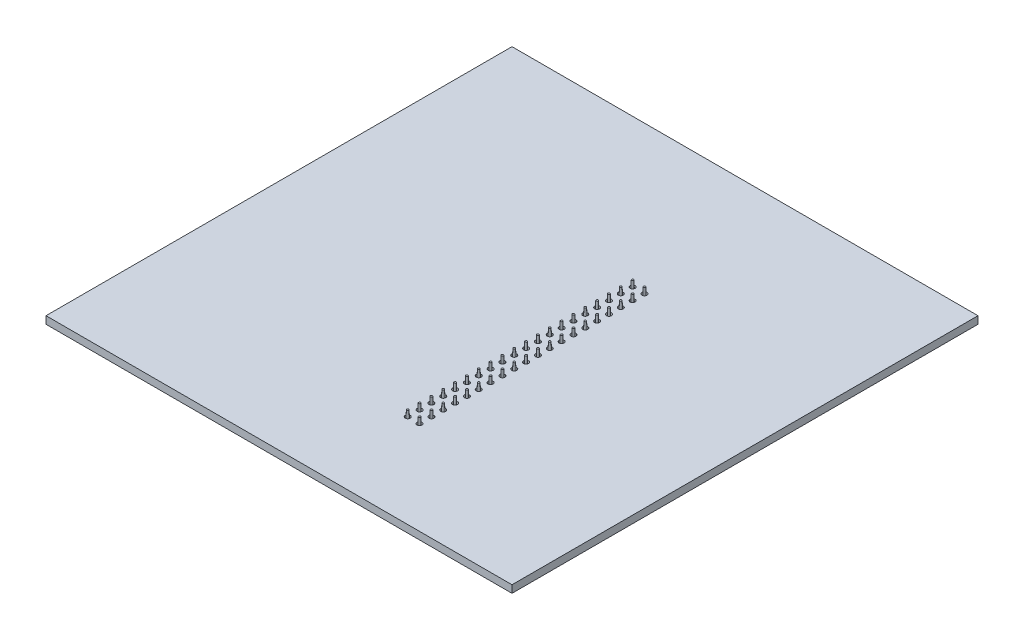
from build123d import *

# Parameters (mm, degrees)
SKETCH1_W              = 100
SKETCH1_H              = 100
BOSS_EXTRUDE1_DEPTH    = 1.6
SKETCH2_R              = 0.535
CUT_EXTRUDE1_DEPTH     = 2.6
SKETCH4_W              = 2.54
SKETCH4_H              = 2.54
SKETCH4_W_2            = 1.54
SKETCH4_H_2            = 1.54
BOSS_EXTRUDE2_DEPTH    = 8.4
LPATTERN2_COUNT        = 20
LPATTERN2_PITCH        = 2.54
LPATTERN2_COUNT_DIR2   = 2
LPATTERN2_PITCH_DIR2   = 2.54
SKETCH5_R              = 0.535
BOSS_EXTRUDE3_DEPTH    = 12.3
BOSS_EXTRUDE3_TAPER    = 1.5
BOSS_EXTRUDE3_2_DEPTH  = 12.3
BOSS_EXTRUDE3_2_TAPER  = 1.5
BOSS_EXTRUDE3_3_DEPTH  = 12.3
BOSS_EXTRUDE3_3_TAPER  = 1.5
BOSS_EXTRUDE3_4_DEPTH  = 12.3
BOSS_EXTRUDE3_4_TAPER  = 1.5
BOSS_EXTRUDE3_5_DEPTH  = 12.3
BOSS_EXTRUDE3_5_TAPER  = 1.5
BOSS_EXTRUDE3_6_DEPTH  = 12.3
BOSS_EXTRUDE3_6_TAPER  = 1.5
BOSS_EXTRUDE3_7_DEPTH  = 12.3
BOSS_EXTRUDE3_7_TAPER  = 1.5
BOSS_EXTRUDE3_8_DEPTH  = 12.3
BOSS_EXTRUDE3_8_TAPER  = 1.5
BOSS_EXTRUDE3_9_DEPTH  = 12.3
BOSS_EXTRUDE3_9_TAPER  = 1.5
BOSS_EXTRUDE3_10_DEPTH = 12.3
BOSS_EXTRUDE3_10_TAPER = 1.5
BOSS_EXTRUDE3_11_DEPTH = 12.3
BOSS_EXTRUDE3_11_TAPER = 1.5
BOSS_EXTRUDE3_12_DEPTH = 12.3
BOSS_EXTRUDE3_12_TAPER = 1.5
BOSS_EXTRUDE3_13_DEPTH = 12.3
BOSS_EXTRUDE3_13_TAPER = 1.5
BOSS_EXTRUDE3_14_DEPTH = 12.3
BOSS_EXTRUDE3_14_TAPER = 1.5
BOSS_EXTRUDE3_15_DEPTH = 12.3
BOSS_EXTRUDE3_15_TAPER = 1.5
BOSS_EXTRUDE3_16_DEPTH = 12.3
BOSS_EXTRUDE3_16_TAPER = 1.5
BOSS_EXTRUDE3_17_DEPTH = 12.3
BOSS_EXTRUDE3_17_TAPER = 1.5
BOSS_EXTRUDE3_18_DEPTH = 12.3
BOSS_EXTRUDE3_18_TAPER = 1.5
BOSS_EXTRUDE3_19_DEPTH = 12.3
BOSS_EXTRUDE3_19_TAPER = 1.5
BOSS_EXTRUDE3_20_DEPTH = 12.3
BOSS_EXTRUDE3_20_TAPER = 1.5
BOSS_EXTRUDE3_21_DEPTH = 12.3
BOSS_EXTRUDE3_21_TAPER = 1.5
BOSS_EXTRUDE3_22_DEPTH = 12.3
BOSS_EXTRUDE3_22_TAPER = 1.5
BOSS_EXTRUDE3_23_DEPTH = 12.3
BOSS_EXTRUDE3_23_TAPER = 1.5
BOSS_EXTRUDE3_24_DEPTH = 12.3
BOSS_EXTRUDE3_24_TAPER = 1.5
BOSS_EXTRUDE3_25_DEPTH = 12.3
BOSS_EXTRUDE3_25_TAPER = 1.5
BOSS_EXTRUDE3_26_DEPTH = 12.3
BOSS_EXTRUDE3_26_TAPER = 1.5
BOSS_EXTRUDE3_27_DEPTH = 12.3
BOSS_EXTRUDE3_27_TAPER = 1.5
BOSS_EXTRUDE3_28_DEPTH = 12.3
BOSS_EXTRUDE3_28_TAPER = 1.5
BOSS_EXTRUDE3_29_DEPTH = 12.3
BOSS_EXTRUDE3_29_TAPER = 1.5
BOSS_EXTRUDE3_30_DEPTH = 12.3
BOSS_EXTRUDE3_30_TAPER = 1.5
BOSS_EXTRUDE3_31_DEPTH = 12.3
BOSS_EXTRUDE3_31_TAPER = 1.5
BOSS_EXTRUDE3_32_DEPTH = 12.3
BOSS_EXTRUDE3_32_TAPER = 1.5
BOSS_EXTRUDE3_33_DEPTH = 12.3
BOSS_EXTRUDE3_33_TAPER = 1.5
BOSS_EXTRUDE3_34_DEPTH = 12.3
BOSS_EXTRUDE3_34_TAPER = 1.5
BOSS_EXTRUDE3_35_DEPTH = 12.3
BOSS_EXTRUDE3_35_TAPER = 1.5
BOSS_EXTRUDE3_36_DEPTH = 12.3
BOSS_EXTRUDE3_36_TAPER = 1.5
BOSS_EXTRUDE3_37_DEPTH = 12.3
BOSS_EXTRUDE3_37_TAPER = 1.5
BOSS_EXTRUDE3_38_DEPTH = 12.3
BOSS_EXTRUDE3_38_TAPER = 1.5
BOSS_EXTRUDE3_39_DEPTH = 12.3
BOSS_EXTRUDE3_39_TAPER = 1.5
BOSS_EXTRUDE3_40_DEPTH = 12.3
BOSS_EXTRUDE3_40_TAPER = 1.5


with BuildPart() as part:
    # Sketch1 → Boss-Extrude1 (new body)
    with BuildSketch(Plane(origin=(0, 0, 0), x_dir=(1, 0, 0), z_dir=(0, 1, 0))):
        Rectangle(SKETCH1_W, SKETCH1_H)
    extrude(amount=BOSS_EXTRUDE1_DEPTH)

    # Sketch2 → Cut-Extrude1 (cut, through all)
    with BuildSketch(Plane(origin=(0, 1.6, 0), x_dir=(1, 0, 0), z_dir=(0, 1, 0))):
        with Locations((10.138, -29.974)):
            Circle(SKETCH2_R)
        with Locations((7.598, -29.974)):
            Circle(SKETCH2_R)
        with Locations((7.598, -27.434)):
            Circle(SKETCH2_R)
        with Locations((7.598, -24.894)):
            Circle(SKETCH2_R)
        with Locations((7.598, -22.354)):
            Circle(SKETCH2_R)
        with Locations((7.598, -19.814)):
            Circle(SKETCH2_R)
        with Locations((7.598, -17.274)):
            Circle(SKETCH2_R)
        with Locations((7.598, -14.734)):
            Circle(SKETCH2_R)
        with Locations((7.598, -12.194)):
            Circle(SKETCH2_R)
        with Locations((7.598, -9.654)):
            Circle(SKETCH2_R)
        with Locations((7.598, -7.114)):
            Circle(SKETCH2_R)
        with Locations((7.598, -4.574)):
            Circle(SKETCH2_R)
        with Locations((7.598, -2.034)):
            Circle(SKETCH2_R)
        with Locations((7.598, 0.506)):
            Circle(SKETCH2_R)
        with Locations((7.598, 3.046)):
            Circle(SKETCH2_R)
        with Locations((7.598, 5.586)):
            Circle(SKETCH2_R)
        with Locations((7.598, 8.126)):
            Circle(SKETCH2_R)
        with Locations((7.598, 10.666)):
            Circle(SKETCH2_R)
        with Locations((7.598, 13.206)):
            Circle(SKETCH2_R)
        with Locations((7.598, 15.746)):
            Circle(SKETCH2_R)
        with Locations((7.598, 18.286)):
            Circle(SKETCH2_R)
        with Locations((10.138, -27.434)):
            Circle(SKETCH2_R)
        with Locations((10.138, -24.894)):
            Circle(SKETCH2_R)
        with Locations((10.138, -22.354)):
            Circle(SKETCH2_R)
        with Locations((10.138, -19.814)):
            Circle(SKETCH2_R)
        with Locations((10.138, -17.274)):
            Circle(SKETCH2_R)
        with Locations((10.138, -14.734)):
            Circle(SKETCH2_R)
        with Locations((10.138, -12.194)):
            Circle(SKETCH2_R)
        with Locations((10.138, -9.654)):
            Circle(SKETCH2_R)
        with Locations((10.138, -7.114)):
            Circle(SKETCH2_R)
        with Locations((10.138, -4.574)):
            Circle(SKETCH2_R)
        with Locations((10.138, -2.034)):
            Circle(SKETCH2_R)
        with Locations((10.138, 0.506)):
            Circle(SKETCH2_R)
        with Locations((10.138, 3.046)):
            Circle(SKETCH2_R)
        with Locations((10.138, 5.586)):
            Circle(SKETCH2_R)
        with Locations((10.138, 8.126)):
            Circle(SKETCH2_R)
        with Locations((10.138, 10.666)):
            Circle(SKETCH2_R)
        with Locations((10.138, 13.206)):
            Circle(SKETCH2_R)
        with Locations((10.138, 15.746)):
            Circle(SKETCH2_R)
        with Locations((10.138, 18.286)):
            Circle(SKETCH2_R)
    extrude(amount=-CUT_EXTRUDE1_DEPTH, mode=Mode.SUBTRACT)


with BuildPart() as body_2:
    # Sketch4 → Boss-Extrude2 (new body)
    with BuildSketch(Plane(origin=(0, -9.4, 0), x_dir=(1, 0, 0), z_dir=(0, 1, 0))):
        with Locations((10.138, -29.974)):
            Rectangle(SKETCH4_W, SKETCH4_H)
        with Locations((10.138, -29.974)):
            Rectangle(SKETCH4_W_2, SKETCH4_H_2, mode=Mode.SUBTRACT)
    boss_extrude2 = extrude(amount=-BOSS_EXTRUDE2_DEPTH)

    # LPattern2: Boss-Extrude2 20 × 2
    with Locations(*[(-j * LPATTERN2_PITCH_DIR2, 0, -i * LPATTERN2_PITCH) for i in range(LPATTERN2_COUNT) for j in range(LPATTERN2_COUNT_DIR2) if (i, j) != (0, 0)]):
        add(boss_extrude2)


with BuildPart() as body_3:
    # Sketch5 → Boss-Extrude3 (new body)
    with BuildSketch(Plane(origin=(0, -9.4, 0), x_dir=(-1, 0, 0), z_dir=(0, -1, 0))):
        with Locations((-7.598, 3.046)):
            Circle(SKETCH5_R)
    extrude(amount=-BOSS_EXTRUDE3_DEPTH, taper=BOSS_EXTRUDE3_TAPER)


with BuildPart() as body_4:
    # Sketch5 → Boss-Extrude3 2 (new body)
    with BuildSketch(Plane(origin=(0, -9.4, 0), x_dir=(-1, 0, 0), z_dir=(0, -1, 0))):
        with Locations((-7.598, 5.586)):
            Circle(SKETCH5_R)
    extrude(amount=-BOSS_EXTRUDE3_2_DEPTH, taper=BOSS_EXTRUDE3_2_TAPER)


with BuildPart() as body_5:
    # Sketch5 → Boss-Extrude3 3 (new body)
    with BuildSketch(Plane(origin=(0, -9.4, 0), x_dir=(-1, 0, 0), z_dir=(0, -1, 0))):
        with Locations((-7.598, 8.126)):
            Circle(SKETCH5_R)
    extrude(amount=-BOSS_EXTRUDE3_3_DEPTH, taper=BOSS_EXTRUDE3_3_TAPER)


with BuildPart() as body_6:
    # Sketch5 → Boss-Extrude3 4 (new body)
    with BuildSketch(Plane(origin=(0, -9.4, 0), x_dir=(-1, 0, 0), z_dir=(0, -1, 0))):
        with Locations((-7.598, 10.666)):
            Circle(SKETCH5_R)
    extrude(amount=-BOSS_EXTRUDE3_4_DEPTH, taper=BOSS_EXTRUDE3_4_TAPER)


with BuildPart() as body_7:
    # Sketch5 → Boss-Extrude3 5 (new body)
    with BuildSketch(Plane(origin=(0, -9.4, 0), x_dir=(-1, 0, 0), z_dir=(0, -1, 0))):
        with Locations((-7.598, 13.206)):
            Circle(SKETCH5_R)
    extrude(amount=-BOSS_EXTRUDE3_5_DEPTH, taper=BOSS_EXTRUDE3_5_TAPER)


with BuildPart() as body_8:
    # Sketch5 → Boss-Extrude3 6 (new body)
    with BuildSketch(Plane(origin=(0, -9.4, 0), x_dir=(-1, 0, 0), z_dir=(0, -1, 0))):
        with Locations((-7.598, 15.746)):
            Circle(SKETCH5_R)
    extrude(amount=-BOSS_EXTRUDE3_6_DEPTH, taper=BOSS_EXTRUDE3_6_TAPER)


with BuildPart() as body_9:
    # Sketch5 → Boss-Extrude3 7 (new body)
    with BuildSketch(Plane(origin=(0, -9.4, 0), x_dir=(-1, 0, 0), z_dir=(0, -1, 0))):
        with Locations((-7.598, 18.286)):
            Circle(SKETCH5_R)
    extrude(amount=-BOSS_EXTRUDE3_7_DEPTH, taper=BOSS_EXTRUDE3_7_TAPER)


with BuildPart() as body_10:
    # Sketch5 → Boss-Extrude3 8 (new body)
    with BuildSketch(Plane(origin=(0, -9.4, 0), x_dir=(-1, 0, 0), z_dir=(0, -1, 0))):
        with Locations((-10.138, 18.286)):
            Circle(SKETCH5_R)
    extrude(amount=-BOSS_EXTRUDE3_8_DEPTH, taper=BOSS_EXTRUDE3_8_TAPER)


with BuildPart() as body_11:
    # Sketch5 → Boss-Extrude3 9 (new body)
    with BuildSketch(Plane(origin=(0, -9.4, 0), x_dir=(-1, 0, 0), z_dir=(0, -1, 0))):
        with Locations((-10.138, 15.746)):
            Circle(SKETCH5_R)
    extrude(amount=-BOSS_EXTRUDE3_9_DEPTH, taper=BOSS_EXTRUDE3_9_TAPER)


with BuildPart() as body_12:
    # Sketch5 → Boss-Extrude3 10 (new body)
    with BuildSketch(Plane(origin=(0, -9.4, 0), x_dir=(-1, 0, 0), z_dir=(0, -1, 0))):
        with Locations((-10.138, 13.206)):
            Circle(SKETCH5_R)
    extrude(amount=-BOSS_EXTRUDE3_10_DEPTH, taper=BOSS_EXTRUDE3_10_TAPER)


with BuildPart() as body_13:
    # Sketch5 → Boss-Extrude3 11 (new body)
    with BuildSketch(Plane(origin=(0, -9.4, 0), x_dir=(-1, 0, 0), z_dir=(0, -1, 0))):
        with Locations((-10.138, 10.666)):
            Circle(SKETCH5_R)
    extrude(amount=-BOSS_EXTRUDE3_11_DEPTH, taper=BOSS_EXTRUDE3_11_TAPER)


with BuildPart() as body_14:
    # Sketch5 → Boss-Extrude3 12 (new body)
    with BuildSketch(Plane(origin=(0, -9.4, 0), x_dir=(-1, 0, 0), z_dir=(0, -1, 0))):
        with Locations((-10.138, 8.126)):
            Circle(SKETCH5_R)
    extrude(amount=-BOSS_EXTRUDE3_12_DEPTH, taper=BOSS_EXTRUDE3_12_TAPER)


with BuildPart() as body_15:
    # Sketch5 → Boss-Extrude3 13 (new body)
    with BuildSketch(Plane(origin=(0, -9.4, 0), x_dir=(-1, 0, 0), z_dir=(0, -1, 0))):
        with Locations((-10.138, 5.586)):
            Circle(SKETCH5_R)
    extrude(amount=-BOSS_EXTRUDE3_13_DEPTH, taper=BOSS_EXTRUDE3_13_TAPER)


with BuildPart() as body_16:
    # Sketch5 → Boss-Extrude3 14 (new body)
    with BuildSketch(Plane(origin=(0, -9.4, 0), x_dir=(-1, 0, 0), z_dir=(0, -1, 0))):
        with Locations((-10.138, 3.046)):
            Circle(SKETCH5_R)
    extrude(amount=-BOSS_EXTRUDE3_14_DEPTH, taper=BOSS_EXTRUDE3_14_TAPER)


with BuildPart() as body_17:
    # Sketch5 → Boss-Extrude3 15 (new body)
    with BuildSketch(Plane(origin=(0, -9.4, 0), x_dir=(-1, 0, 0), z_dir=(0, -1, 0))):
        with Locations((-7.598, 0.506)):
            Circle(SKETCH5_R)
    extrude(amount=-BOSS_EXTRUDE3_15_DEPTH, taper=BOSS_EXTRUDE3_15_TAPER)


with BuildPart() as body_18:
    # Sketch5 → Boss-Extrude3 16 (new body)
    with BuildSketch(Plane(origin=(0, -9.4, 0), x_dir=(-1, 0, 0), z_dir=(0, -1, 0))):
        with Locations((-10.138, 0.506)):
            Circle(SKETCH5_R)
    extrude(amount=-BOSS_EXTRUDE3_16_DEPTH, taper=BOSS_EXTRUDE3_16_TAPER)


with BuildPart() as body_19:
    # Sketch5 → Boss-Extrude3 17 (new body)
    with BuildSketch(Plane(origin=(0, -9.4, 0), x_dir=(-1, 0, 0), z_dir=(0, -1, 0))):
        with Locations((-10.138, -2.034)):
            Circle(SKETCH5_R)
    extrude(amount=-BOSS_EXTRUDE3_17_DEPTH, taper=BOSS_EXTRUDE3_17_TAPER)


with BuildPart() as body_20:
    # Sketch5 → Boss-Extrude3 18 (new body)
    with BuildSketch(Plane(origin=(0, -9.4, 0), x_dir=(-1, 0, 0), z_dir=(0, -1, 0))):
        with Locations((-7.598, -2.034)):
            Circle(SKETCH5_R)
    extrude(amount=-BOSS_EXTRUDE3_18_DEPTH, taper=BOSS_EXTRUDE3_18_TAPER)


with BuildPart() as body_21:
    # Sketch5 → Boss-Extrude3 19 (new body)
    with BuildSketch(Plane(origin=(0, -9.4, 0), x_dir=(-1, 0, 0), z_dir=(0, -1, 0))):
        with Locations((-7.598, -4.574)):
            Circle(SKETCH5_R)
    extrude(amount=-BOSS_EXTRUDE3_19_DEPTH, taper=BOSS_EXTRUDE3_19_TAPER)


with BuildPart() as body_22:
    # Sketch5 → Boss-Extrude3 20 (new body)
    with BuildSketch(Plane(origin=(0, -9.4, 0), x_dir=(-1, 0, 0), z_dir=(0, -1, 0))):
        with Locations((-10.138, -4.574)):
            Circle(SKETCH5_R)
    extrude(amount=-BOSS_EXTRUDE3_20_DEPTH, taper=BOSS_EXTRUDE3_20_TAPER)


with BuildPart() as body_23:
    # Sketch5 → Boss-Extrude3 21 (new body)
    with BuildSketch(Plane(origin=(0, -9.4, 0), x_dir=(-1, 0, 0), z_dir=(0, -1, 0))):
        with Locations((-10.138, -7.114)):
            Circle(SKETCH5_R)
    extrude(amount=-BOSS_EXTRUDE3_21_DEPTH, taper=BOSS_EXTRUDE3_21_TAPER)


with BuildPart() as body_24:
    # Sketch5 → Boss-Extrude3 22 (new body)
    with BuildSketch(Plane(origin=(0, -9.4, 0), x_dir=(-1, 0, 0), z_dir=(0, -1, 0))):
        with Locations((-7.598, -7.114)):
            Circle(SKETCH5_R)
    extrude(amount=-BOSS_EXTRUDE3_22_DEPTH, taper=BOSS_EXTRUDE3_22_TAPER)


with BuildPart() as body_25:
    # Sketch5 → Boss-Extrude3 23 (new body)
    with BuildSketch(Plane(origin=(0, -9.4, 0), x_dir=(-1, 0, 0), z_dir=(0, -1, 0))):
        with Locations((-7.598, -9.654)):
            Circle(SKETCH5_R)
    extrude(amount=-BOSS_EXTRUDE3_23_DEPTH, taper=BOSS_EXTRUDE3_23_TAPER)


with BuildPart() as body_26:
    # Sketch5 → Boss-Extrude3 24 (new body)
    with BuildSketch(Plane(origin=(0, -9.4, 0), x_dir=(-1, 0, 0), z_dir=(0, -1, 0))):
        with Locations((-10.138, -9.654)):
            Circle(SKETCH5_R)
    extrude(amount=-BOSS_EXTRUDE3_24_DEPTH, taper=BOSS_EXTRUDE3_24_TAPER)


with BuildPart() as body_27:
    # Sketch5 → Boss-Extrude3 25 (new body)
    with BuildSketch(Plane(origin=(0, -9.4, 0), x_dir=(-1, 0, 0), z_dir=(0, -1, 0))):
        with Locations((-7.598, -12.194)):
            Circle(SKETCH5_R)
    extrude(amount=-BOSS_EXTRUDE3_25_DEPTH, taper=BOSS_EXTRUDE3_25_TAPER)


with BuildPart() as body_28:
    # Sketch5 → Boss-Extrude3 26 (new body)
    with BuildSketch(Plane(origin=(0, -9.4, 0), x_dir=(-1, 0, 0), z_dir=(0, -1, 0))):
        with Locations((-10.138, -12.194)):
            Circle(SKETCH5_R)
    extrude(amount=-BOSS_EXTRUDE3_26_DEPTH, taper=BOSS_EXTRUDE3_26_TAPER)


with BuildPart() as body_29:
    # Sketch5 → Boss-Extrude3 27 (new body)
    with BuildSketch(Plane(origin=(0, -9.4, 0), x_dir=(-1, 0, 0), z_dir=(0, -1, 0))):
        with Locations((-10.138, -14.734)):
            Circle(SKETCH5_R)
    extrude(amount=-BOSS_EXTRUDE3_27_DEPTH, taper=BOSS_EXTRUDE3_27_TAPER)


with BuildPart() as body_30:
    # Sketch5 → Boss-Extrude3 28 (new body)
    with BuildSketch(Plane(origin=(0, -9.4, 0), x_dir=(-1, 0, 0), z_dir=(0, -1, 0))):
        with Locations((-7.598, -14.734)):
            Circle(SKETCH5_R)
    extrude(amount=-BOSS_EXTRUDE3_28_DEPTH, taper=BOSS_EXTRUDE3_28_TAPER)


with BuildPart() as body_31:
    # Sketch5 → Boss-Extrude3 29 (new body)
    with BuildSketch(Plane(origin=(0, -9.4, 0), x_dir=(-1, 0, 0), z_dir=(0, -1, 0))):
        with Locations((-7.598, -17.274)):
            Circle(SKETCH5_R)
    extrude(amount=-BOSS_EXTRUDE3_29_DEPTH, taper=BOSS_EXTRUDE3_29_TAPER)


with BuildPart() as body_32:
    # Sketch5 → Boss-Extrude3 30 (new body)
    with BuildSketch(Plane(origin=(0, -9.4, 0), x_dir=(-1, 0, 0), z_dir=(0, -1, 0))):
        with Locations((-10.138, -17.274)):
            Circle(SKETCH5_R)
    extrude(amount=-BOSS_EXTRUDE3_30_DEPTH, taper=BOSS_EXTRUDE3_30_TAPER)


with BuildPart() as body_33:
    # Sketch5 → Boss-Extrude3 31 (new body)
    with BuildSketch(Plane(origin=(0, -9.4, 0), x_dir=(-1, 0, 0), z_dir=(0, -1, 0))):
        with Locations((-10.138, -19.814)):
            Circle(SKETCH5_R)
    extrude(amount=-BOSS_EXTRUDE3_31_DEPTH, taper=BOSS_EXTRUDE3_31_TAPER)


with BuildPart() as body_34:
    # Sketch5 → Boss-Extrude3 32 (new body)
    with BuildSketch(Plane(origin=(0, -9.4, 0), x_dir=(-1, 0, 0), z_dir=(0, -1, 0))):
        with Locations((-7.598, -19.814)):
            Circle(SKETCH5_R)
    extrude(amount=-BOSS_EXTRUDE3_32_DEPTH, taper=BOSS_EXTRUDE3_32_TAPER)


with BuildPart() as body_35:
    # Sketch5 → Boss-Extrude3 33 (new body)
    with BuildSketch(Plane(origin=(0, -9.4, 0), x_dir=(-1, 0, 0), z_dir=(0, -1, 0))):
        with Locations((-7.598, -22.354)):
            Circle(SKETCH5_R)
    extrude(amount=-BOSS_EXTRUDE3_33_DEPTH, taper=BOSS_EXTRUDE3_33_TAPER)


with BuildPart() as body_36:
    # Sketch5 → Boss-Extrude3 34 (new body)
    with BuildSketch(Plane(origin=(0, -9.4, 0), x_dir=(-1, 0, 0), z_dir=(0, -1, 0))):
        with Locations((-10.138, -22.354)):
            Circle(SKETCH5_R)
    extrude(amount=-BOSS_EXTRUDE3_34_DEPTH, taper=BOSS_EXTRUDE3_34_TAPER)


with BuildPart() as body_37:
    # Sketch5 → Boss-Extrude3 35 (new body)
    with BuildSketch(Plane(origin=(0, -9.4, 0), x_dir=(-1, 0, 0), z_dir=(0, -1, 0))):
        with Locations((-7.598, -24.894)):
            Circle(SKETCH5_R)
    extrude(amount=-BOSS_EXTRUDE3_35_DEPTH, taper=BOSS_EXTRUDE3_35_TAPER)


with BuildPart() as body_38:
    # Sketch5 → Boss-Extrude3 36 (new body)
    with BuildSketch(Plane(origin=(0, -9.4, 0), x_dir=(-1, 0, 0), z_dir=(0, -1, 0))):
        with Locations((-10.138, -24.894)):
            Circle(SKETCH5_R)
    extrude(amount=-BOSS_EXTRUDE3_36_DEPTH, taper=BOSS_EXTRUDE3_36_TAPER)


with BuildPart() as body_39:
    # Sketch5 → Boss-Extrude3 37 (new body)
    with BuildSketch(Plane(origin=(0, -9.4, 0), x_dir=(-1, 0, 0), z_dir=(0, -1, 0))):
        with Locations((-7.598, -27.434)):
            Circle(SKETCH5_R)
    extrude(amount=-BOSS_EXTRUDE3_37_DEPTH, taper=BOSS_EXTRUDE3_37_TAPER)


with BuildPart() as body_40:
    # Sketch5 → Boss-Extrude3 38 (new body)
    with BuildSketch(Plane(origin=(0, -9.4, 0), x_dir=(-1, 0, 0), z_dir=(0, -1, 0))):
        with Locations((-10.138, -27.434)):
            Circle(SKETCH5_R)
    extrude(amount=-BOSS_EXTRUDE3_38_DEPTH, taper=BOSS_EXTRUDE3_38_TAPER)


with BuildPart() as body_41:
    # Sketch5 → Boss-Extrude3 39 (new body)
    with BuildSketch(Plane(origin=(0, -9.4, 0), x_dir=(-1, 0, 0), z_dir=(0, -1, 0))):
        with Locations((-10.138, -29.974)):
            Circle(SKETCH5_R)
    extrude(amount=-BOSS_EXTRUDE3_39_DEPTH, taper=BOSS_EXTRUDE3_39_TAPER)


with BuildPart() as body_42:
    # Sketch5 → Boss-Extrude3 40 (new body)
    with BuildSketch(Plane(origin=(0, -9.4, 0), x_dir=(-1, 0, 0), z_dir=(0, -1, 0))):
        with Locations((-7.598, -29.974)):
            Circle(SKETCH5_R)
    extrude(amount=-BOSS_EXTRUDE3_40_DEPTH, taper=BOSS_EXTRUDE3_40_TAPER)


solid = Compound([part.part, body_2.part, body_3.part, body_4.part, body_5.part, body_6.part, body_7.part, body_8.part, body_9.part, body_10.part, body_11.part, body_12.part, body_13.part, body_14.part, body_15.part, body_16.part, body_17.part, body_18.part, body_19.part, body_20.part, body_21.part, body_22.part, body_23.part, body_24.part, body_25.part, body_26.part, body_27.part, body_28.part, body_29.part, body_30.part, body_31.part, body_32.part, body_33.part, body_34.part, body_35.part, body_36.part, body_37.part, body_38.part, body_39.part, body_40.part, body_41.part, body_42.part])
